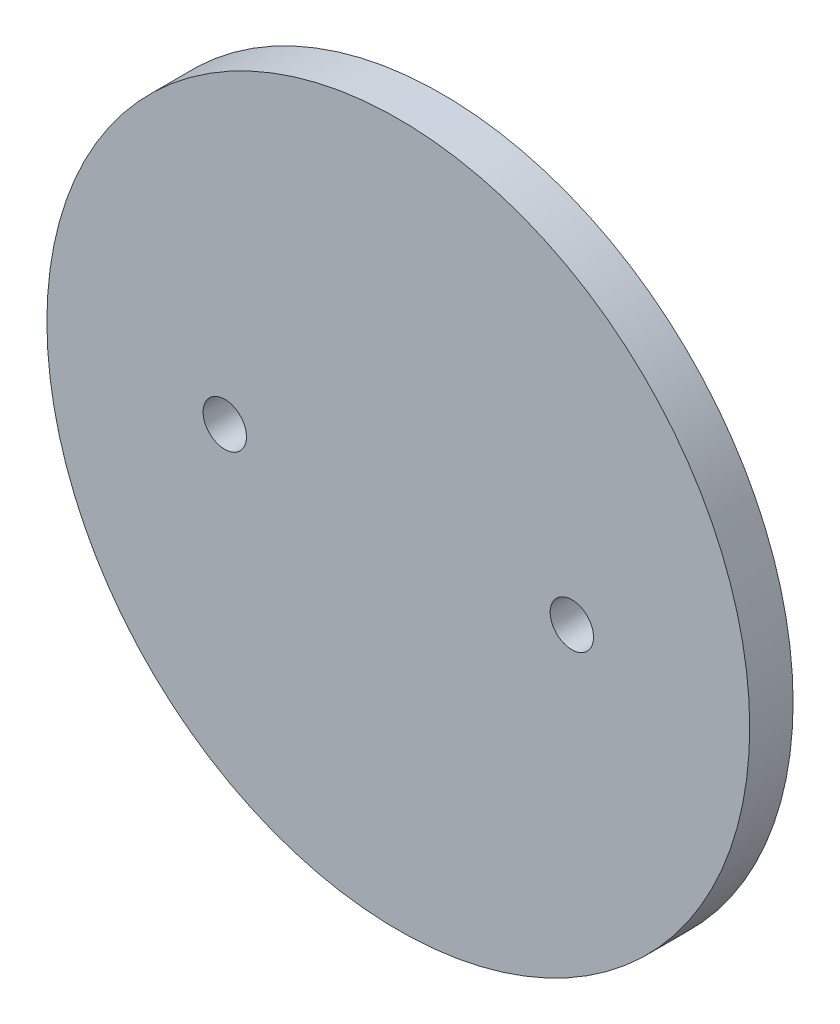
from build123d import *

# Parameters (mm, degrees)
SKETCH1_R           = 20.575
BOSS_EXTRUDE1_DEPTH = 2.54
CUT_EXTRUDE1_DEPTH  = 3.54


with BuildPart() as part:
    # Sketch1 → Boss-Extrude1 (new body)
    with BuildSketch(Plane.XY):
        Circle(SKETCH1_R)
    extrude(amount=BOSS_EXTRUDE1_DEPTH)

    # Sketch2 → Cut-Extrude1 (cut, through all)
    with BuildSketch(Plane.XY.offset(2.54)):
        with BuildLine():
            ThreePointArc((-8.89, 0), (-10.16, 1.27), (-11.43, 0))
            Line((-11.43, 0), (-8.89, 0))
        make_face()
        with BuildLine():
            Line((-8.89, 0), (-11.43, 0))
            ThreePointArc((-11.43, 0), (-10.16, -1.27), (-8.89, 0))
        make_face()
        with BuildLine():
            ThreePointArc((11.43, 0), (10.16, 1.27), (8.89, 0))
            Line((8.89, 0), (11.43, 0))
        make_face()
        with BuildLine():
            Line((11.43, 0), (8.89, 0))
            ThreePointArc((8.89, 0), (10.16, -1.27), (11.43, 0))
        make_face()
    extrude(amount=-CUT_EXTRUDE1_DEPTH, mode=Mode.SUBTRACT)


solid = part.part
